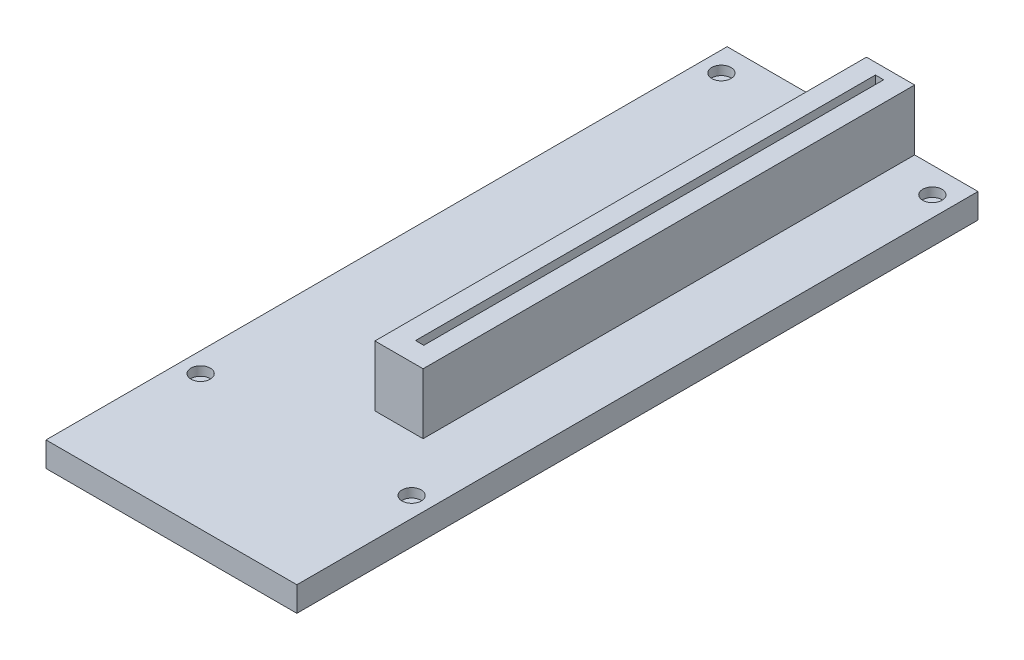
from build123d import *

# Parameters (mm, degrees)
SKETCH1_W           = 45.55
SKETCH1_H           = 123.67
SKETCH1_R           = 1.75
BOSS_EXTRUDE1_DEPTH = 1.65
SKETCH2_W           = 45.55
SKETCH2_H           = 123.67
BOSS_EXTRUDE2_DEPTH = 2.85
SKETCH3_W           = 8.75
SKETCH3_H           = 89.25
BOSS_EXTRUDE3_DEPTH = 11
SKETCH4_W           = 1.5
SKETCH4_H           = 83.5
CUT_EXTRUDE1_DEPTH  = 7


with BuildPart() as part:
    # Sketch1 → Boss-Extrude1 (new body)
    with BuildSketch(Plane(origin=(0, 0, 0), x_dir=(1, 0, 0), z_dir=(0, 1, 0))):
        Rectangle(SKETCH1_W, SKETCH1_H)
        with Locations((-19.154293565, -37.379539044)):
            Circle(SKETCH1_R, mode=Mode.SUBTRACT)
        with Locations((-19.154293565, 57.171070526)):
            Circle(SKETCH1_R, mode=Mode.SUBTRACT)
        with Locations((19.154293565, -37.379539044)):
            Circle(SKETCH1_R, mode=Mode.SUBTRACT)
        with Locations((19.154293565, 57.171070526)):
            Circle(SKETCH1_R, mode=Mode.SUBTRACT)
    extrude(amount=BOSS_EXTRUDE1_DEPTH)

    # Sketch2 → Boss-Extrude2 (add)
    with BuildSketch(Plane.XZ):
        Rectangle(SKETCH2_W, SKETCH2_H)
    extrude(amount=BOSS_EXTRUDE2_DEPTH)

    # Sketch3 → Boss-Extrude3 (add)
    with BuildSketch(Plane(origin=(0, 1.65, 0), x_dir=(1, 0, 0), z_dir=(0, 1, 0))):
        with Locations((6.9, 17.21)):
            Rectangle(SKETCH3_W, SKETCH3_H)
    extrude(amount=BOSS_EXTRUDE3_DEPTH)

    # Sketch4 → Cut-Extrude1 (cut)
    with BuildSketch(Plane(origin=(0, 12.65, 0), x_dir=(1, 0, 0), z_dir=(0, 1, 0))):
        with Locations((6.9, 18.085)):
            Rectangle(SKETCH4_W, SKETCH4_H)
    extrude(amount=-CUT_EXTRUDE1_DEPTH, mode=Mode.SUBTRACT)


solid = part.part
